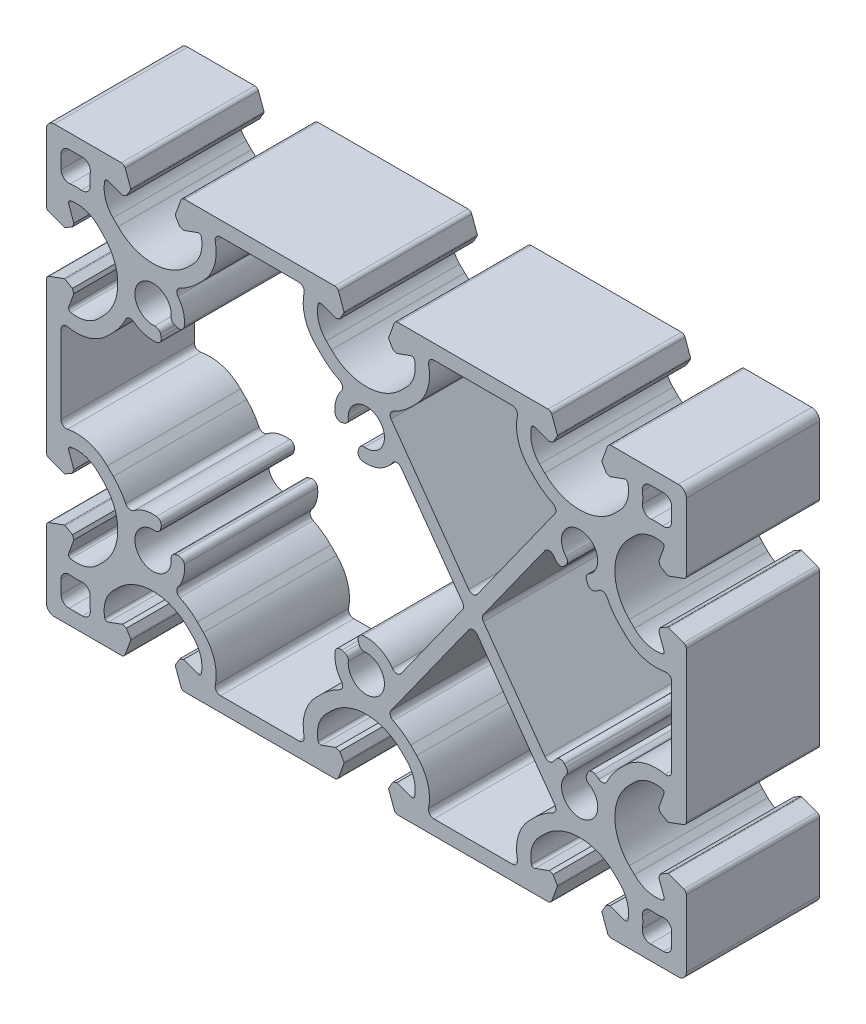
from build123d import *

# Parameters (mm, degrees)
MAIN_EXTRUSION_DEPTH = 25


with BuildPart() as part:
    # Sk Main Extrusion → Main Extrusion (new body)
    with BuildSketch(Plane.XY):
        with BuildLine():
            Line((-35.809923155, -36.671180212), (-34.777945649, -39.506515107))
            ThreePointArc((-34.777945649, -39.506515107), (-34.503358511, -39.864364033), (-34.073176184, -40))
            Line((-34.073176184, -40), (-5.926823816, -40))
            ThreePointArc((-5.926823816, -40), (-5.496641489, -39.864364033), (-5.222054351, -39.506515107))
            Line((-5.222054351, -39.506515107), (-4.190076845, -36.671180212))
            ThreePointArc((-4.190076845, -36.671180212), (-4.175951325, -36.563886241), (-4.208493649, -36.460675177))
            Line((-4.208493649, -36.460675177), (-4.987558066, -35.111296024))
            Line((-4.987558066, -35.111296024), (-5.718509166, -34.845251581))
            Line((-5.718509166, -34.845251581), (-8.396186179, -35.81984631))
            ThreePointArc((-8.396186179, -35.81984631), (-8.811074612, -35.786489799), (-9.056960151, -35.450654467))
            ThreePointArc((-9.056960151, -35.450654467), (-8.933433013, -32.665882372), (-7.504160339, -30.272684887))
            Line((-7.504160339, -30.272684887), (-6.540737726, -29.309262274))
            ThreePointArc((-6.540737726, -29.309262274), (0, -26.6), (6.540737726, -29.309262274))
            Line((6.540737726, -29.309262274), (7.504160339, -30.272684887))
            ThreePointArc((7.504160339, -30.272684887), (8.933433013, -32.665882372), (9.056960151, -35.450654467))
            ThreePointArc((9.056960151, -35.450654467), (8.811074612, -35.786489799), (8.396186179, -35.81984631))
            Line((8.396186179, -35.81984631), (5.718509166, -34.845251581))
            Line((5.718509166, -34.845251581), (4.987558066, -35.111296024))
            Line((4.987558066, -35.111296024), (4.208493649, -36.460675177))
            ThreePointArc((4.208493649, -36.460675177), (4.175951325, -36.563886241), (4.190076845, -36.671180212))
            Line((4.190076845, -36.671180212), (5.222054351, -39.506515107))
            ThreePointArc((5.222054351, -39.506515107), (5.496641489, -39.864364033), (5.926823816, -40))
            Line((5.926823816, -40), (34.073176184, -40))
            ThreePointArc((34.073176184, -40), (34.503358511, -39.864364033), (34.777945649, -39.506515107))
            Line((34.777945649, -39.506515107), (35.809923155, -36.671180212))
            ThreePointArc((35.809923155, -36.671180212), (35.824048675, -36.563886241), (35.791506351, -36.460675177))
            Line((35.791506351, -36.460675177), (35.012441934, -35.111296024))
            Line((35.012441934, -35.111296024), (34.281490834, -34.845251581))
            Line((34.281490834, -34.845251581), (31.603813821, -35.81984631))
            ThreePointArc((31.603813821, -35.81984631), (31.188925388, -35.786489799), (30.943039849, -35.450654467))
            ThreePointArc((30.943039849, -35.450654467), (31.066566987, -32.665882372), (32.495839661, -30.272684887))
            Line((32.495839661, -30.272684887), (33.459262274, -29.309262274))
            ThreePointArc((33.459262274, -29.309262274), (40, -26.6), (46.540737726, -29.309262274))
            Line((46.540737726, -29.309262274), (47.504160339, -30.272684887))
            ThreePointArc((47.504160339, -30.272684887), (48.933433013, -32.665882372), (49.056960151, -35.450654467))
            ThreePointArc((49.056960151, -35.450654467), (48.811074612, -35.786489799), (48.396186179, -35.81984631))
            Line((48.396186179, -35.81984631), (45.718509166, -34.845251581))
            Line((45.718509166, -34.845251581), (44.987558066, -35.111296024))
            Line((44.987558066, -35.111296024), (44.208493649, -36.460675176))
            ThreePointArc((44.208493649, -36.460675176), (44.175951325, -36.563886241), (44.190076845, -36.671180212))
            Line((44.190076845, -36.671180212), (45.222054351, -39.506515107))
            ThreePointArc((45.222054351, -39.506515107), (45.496641489, -39.864364033), (45.926823816, -40))
            Line((45.926823816, -40), (58.5, -40))
            ThreePointArc((58.5, -40), (59.560660172, -39.560660172), (60, -38.5))
            Line((60, -38.5), (60, -25.926823816))
            ThreePointArc((60, -25.926823816), (59.864364033, -25.496641489), (59.506515107, -25.222054351))
            Line((59.506515107, -25.222054351), (56.671180212, -24.190076845))
            ThreePointArc((56.671180212, -24.190076845), (56.563886241, -24.175951325), (56.460675176, -24.208493649))
            Line((56.460675176, -24.208493649), (55.111296024, -24.987558066))
            Line((55.111296024, -24.987558066), (54.845251581, -25.718509166))
            Line((54.845251581, -25.718509166), (55.81984631, -28.396186179))
            ThreePointArc((55.81984631, -28.396186179), (55.786489799, -28.811074612), (55.450654467, -29.056960151))
            ThreePointArc((55.450654467, -29.056960151), (52.665882372, -28.933433013), (50.272684887, -27.504160339))
            Line((50.272684887, -27.504160339), (49.309262274, -26.540737726))
            ThreePointArc((49.309262274, -26.540737726), (46.6, -20), (49.309262274, -13.459262274))
            Line((49.309262274, -13.459262274), (50.272684887, -12.495839661))
            ThreePointArc((50.272684887, -12.495839661), (52.665882372, -11.066566987), (55.450654467, -10.943039849))
            ThreePointArc((55.450654467, -10.943039849), (55.786489799, -11.188925388), (55.81984631, -11.603813821))
            Line((55.81984631, -11.603813821), (54.845251581, -14.281490834))
            Line((54.845251581, -14.281490834), (55.111296024, -15.012441934))
            Line((55.111296024, -15.012441934), (56.460675176, -15.791506351))
            ThreePointArc((56.460675176, -15.791506351), (56.563886241, -15.824048675), (56.671180212, -15.809923155))
            Line((56.671180212, -15.809923155), (59.506515107, -14.777945649))
            ThreePointArc((59.506515107, -14.777945649), (59.864364033, -14.503358511), (60, -14.073176184))
            Line((60, -14.073176184), (60, 14.073176184))
            ThreePointArc((60, 14.073176184), (59.864364033, 14.503358511), (59.506515107, 14.777945649))
            Line((59.506515107, 14.777945649), (56.671180212, 15.809923155))
            ThreePointArc((56.671180212, 15.809923155), (56.563886241, 15.824048675), (56.460675176, 15.791506351))
            Line((56.460675176, 15.791506351), (55.111296024, 15.012441934))
            Line((55.111296024, 15.012441934), (54.845251581, 14.281490834))
            Line((54.845251581, 14.281490834), (55.81984631, 11.603813821))
            ThreePointArc((55.81984631, 11.603813821), (55.786489799, 11.188925388), (55.450654467, 10.943039849))
            ThreePointArc((55.450654467, 10.943039849), (52.665882372, 11.066566987), (50.272684887, 12.495839661))
            Line((50.272684887, 12.495839661), (49.309262274, 13.459262274))
            ThreePointArc((49.309262274, 13.459262274), (46.6, 20), (49.309262274, 26.540737726))
            Line((49.309262274, 26.540737726), (50.272684887, 27.504160339))
            ThreePointArc((50.272684887, 27.504160339), (52.665882372, 28.933433013), (55.450654467, 29.056960151))
            ThreePointArc((55.450654467, 29.056960151), (55.786489799, 28.811074612), (55.81984631, 28.396186179))
            Line((55.81984631, 28.396186179), (54.845251581, 25.718509166))
            Line((54.845251581, 25.718509166), (55.111296024, 24.987558066))
            Line((55.111296024, 24.987558066), (56.460675176, 24.208493649))
            ThreePointArc((56.460675176, 24.208493649), (56.563886241, 24.175951325), (56.671180212, 24.190076845))
            Line((56.671180212, 24.190076845), (59.506515107, 25.222054351))
            ThreePointArc((59.506515107, 25.222054351), (59.864364033, 25.496641489), (60, 25.926823816))
            Line((60, 25.926823816), (60, 38.5))
            ThreePointArc((60, 38.5), (59.560660172, 39.560660172), (58.5, 40))
            Line((58.5, 40), (45.926823816, 40))
            ThreePointArc((45.926823816, 40), (45.496641489, 39.864364033), (45.222054351, 39.506515107))
            Line((45.222054351, 39.506515107), (44.190076845, 36.671180212))
            ThreePointArc((44.190076845, 36.671180212), (44.175951325, 36.563886241), (44.208493649, 36.460675177))
            Line((44.208493649, 36.460675177), (44.987558066, 35.111296024))
            Line((44.987558066, 35.111296024), (45.718509166, 34.845251581))
            Line((45.718509166, 34.845251581), (48.396186179, 35.81984631))
            ThreePointArc((48.396186179, 35.81984631), (48.811074612, 35.786489799), (49.056960151, 35.450654467))
            ThreePointArc((49.056960151, 35.450654467), (48.933433013, 32.665882372), (47.504160339, 30.272684887))
            Line((47.504160339, 30.272684887), (46.540737726, 29.309262274))
            ThreePointArc((46.540737726, 29.309262274), (40, 26.6), (33.459262274, 29.309262274))
            Line((33.459262274, 29.309262274), (32.495839661, 30.272684887))
            ThreePointArc((32.495839661, 30.272684887), (31.066566987, 32.665882372), (30.943039849, 35.450654467))
            ThreePointArc((30.943039849, 35.450654467), (31.188925388, 35.786489799), (31.603813821, 35.81984631))
            Line((31.603813821, 35.81984631), (34.281490834, 34.845251581))
            Line((34.281490834, 34.845251581), (35.012441934, 35.111296024))
            Line((35.012441934, 35.111296024), (35.791506351, 36.460675177))
            ThreePointArc((35.791506351, 36.460675177), (35.824048675, 36.563886241), (35.809923155, 36.671180212))
            Line((35.809923155, 36.671180212), (34.777945649, 39.506515107))
            ThreePointArc((34.777945649, 39.506515107), (34.503358511, 39.864364033), (34.073176184, 40))
            Line((34.073176184, 40), (5.926823816, 40))
            ThreePointArc((5.926823816, 40), (5.496641489, 39.864364033), (5.222054351, 39.506515107))
            Line((5.222054351, 39.506515107), (4.190076845, 36.671180212))
            ThreePointArc((4.190076845, 36.671180212), (4.175951325, 36.563886241), (4.208493649, 36.460675177))
            Line((4.208493649, 36.460675177), (4.987558066, 35.111296024))
            Line((4.987558066, 35.111296024), (5.718509166, 34.845251581))
            Line((5.718509166, 34.845251581), (8.396186179, 35.81984631))
            ThreePointArc((8.396186179, 35.81984631), (8.811074612, 35.786489799), (9.056960151, 35.450654467))
            ThreePointArc((9.056960151, 35.450654467), (8.933433013, 32.665882372), (7.504160339, 30.272684887))
            Line((7.504160339, 30.272684887), (6.540737726, 29.309262274))
            ThreePointArc((6.540737726, 29.309262274), (0, 26.6), (-6.540737726, 29.309262274))
            Line((-6.540737726, 29.309262274), (-7.504160339, 30.272684887))
            ThreePointArc((-7.504160339, 30.272684887), (-8.933433013, 32.665882372), (-9.056960151, 35.450654467))
            ThreePointArc((-9.056960151, 35.450654467), (-8.811074612, 35.786489799), (-8.396186179, 35.81984631))
            Line((-8.396186179, 35.81984631), (-5.718509166, 34.845251581))
            Line((-5.718509166, 34.845251581), (-4.987558066, 35.111296024))
            Line((-4.987558066, 35.111296024), (-4.208493649, 36.460675177))
            ThreePointArc((-4.208493649, 36.460675177), (-4.175951325, 36.563886241), (-4.190076845, 36.671180212))
            Line((-4.190076845, 36.671180212), (-5.222054351, 39.506515107))
            ThreePointArc((-5.222054351, 39.506515107), (-5.496641489, 39.864364033), (-5.926823816, 40))
            Line((-5.926823816, 40), (-34.073176184, 40))
            ThreePointArc((-34.073176184, 40), (-34.503358511, 39.864364033), (-34.777945649, 39.506515107))
            Line((-34.777945649, 39.506515107), (-35.809923155, 36.671180212))
            ThreePointArc((-35.809923155, 36.671180212), (-35.824048675, 36.563886241), (-35.791506351, 36.460675177))
            Line((-35.791506351, 36.460675177), (-35.012441934, 35.111296024))
            Line((-35.012441934, 35.111296024), (-34.281490834, 34.845251581))
            Line((-34.281490834, 34.845251581), (-31.603813821, 35.81984631))
            ThreePointArc((-31.603813821, 35.81984631), (-31.188925388, 35.786489799), (-30.943039849, 35.450654467))
            ThreePointArc((-30.943039849, 35.450654467), (-31.066566987, 32.665882372), (-32.495839661, 30.272684887))
            Line((-32.495839661, 30.272684887), (-33.459262274, 29.309262274))
            ThreePointArc((-33.459262274, 29.309262274), (-40, 26.6), (-46.540737726, 29.309262274))
            Line((-46.540737726, 29.309262274), (-47.504160339, 30.272684887))
            ThreePointArc((-47.504160339, 30.272684887), (-48.933433013, 32.665882372), (-49.056960151, 35.450654467))
            ThreePointArc((-49.056960151, 35.450654467), (-48.811074612, 35.786489799), (-48.396186179, 35.81984631))
            Line((-48.396186179, 35.81984631), (-45.718509166, 34.845251581))
            Line((-45.718509166, 34.845251581), (-44.987558066, 35.111296024))
            Line((-44.987558066, 35.111296024), (-44.208493649, 36.460675177))
            ThreePointArc((-44.208493649, 36.460675177), (-44.175951325, 36.563886241), (-44.190076845, 36.671180212))
            Line((-44.190076845, 36.671180212), (-45.222054351, 39.506515107))
            ThreePointArc((-45.222054351, 39.506515107), (-45.496641489, 39.864364033), (-45.926823816, 40))
            Line((-45.926823816, 40), (-58.5, 40))
            ThreePointArc((-58.5, 40), (-59.560660172, 39.560660172), (-60, 38.5))
            Line((-60, 38.5), (-60, 25.926823816))
            ThreePointArc((-60, 25.926823816), (-59.864364033, 25.496641489), (-59.506515108, 25.222054351))
            Line((-59.506515108, 25.222054351), (-56.671180212, 24.190076845))
            ThreePointArc((-56.671180212, 24.190076845), (-56.563886241, 24.175951325), (-56.460675177, 24.208493649))
            Line((-56.460675177, 24.208493649), (-55.111296024, 24.987558066))
            Line((-55.111296024, 24.987558066), (-54.845251581, 25.718509166))
            Line((-54.845251581, 25.718509166), (-55.81984631, 28.396186179))
            ThreePointArc((-55.81984631, 28.396186179), (-55.786489799, 28.811074612), (-55.450654467, 29.056960151))
            ThreePointArc((-55.450654467, 29.056960151), (-52.665882372, 28.933433013), (-50.272684887, 27.504160339))
            Line((-50.272684887, 27.504160339), (-49.309262274, 26.540737726))
            ThreePointArc((-49.309262274, 26.540737726), (-46.6, 20), (-49.309262274, 13.459262274))
            Line((-49.309262274, 13.459262274), (-50.272684887, 12.495839661))
            ThreePointArc((-50.272684887, 12.495839661), (-52.665882372, 11.066566987), (-55.450654467, 10.943039849))
            ThreePointArc((-55.450654467, 10.943039849), (-55.786489799, 11.188925388), (-55.81984631, 11.603813821))
            Line((-55.81984631, 11.603813821), (-54.845251581, 14.281490834))
            Line((-54.845251581, 14.281490834), (-55.111296024, 15.012441934))
            Line((-55.111296024, 15.012441934), (-56.460675177, 15.791506351))
            ThreePointArc((-56.460675177, 15.791506351), (-56.563886241, 15.824048675), (-56.671180212, 15.809923155))
            Line((-56.671180212, 15.809923155), (-59.506515108, 14.777945649))
            ThreePointArc((-59.506515108, 14.777945649), (-59.864364033, 14.503358511), (-60, 14.073176184))
            Line((-60, 14.073176184), (-60, -14.073176184))
            ThreePointArc((-60, -14.073176184), (-59.864364033, -14.503358511), (-59.506515108, -14.777945649))
            Line((-59.506515108, -14.777945649), (-56.671180212, -15.809923155))
            ThreePointArc((-56.671180212, -15.809923155), (-56.563886241, -15.824048675), (-56.460675177, -15.791506351))
            Line((-56.460675177, -15.791506351), (-55.111296024, -15.012441934))
            Line((-55.111296024, -15.012441934), (-54.845251581, -14.281490834))
            Line((-54.845251581, -14.281490834), (-55.81984631, -11.603813821))
            ThreePointArc((-55.81984631, -11.603813821), (-55.786489799, -11.188925388), (-55.450654467, -10.943039849))
            ThreePointArc((-55.450654467, -10.943039849), (-52.665882372, -11.066566987), (-50.272684887, -12.495839661))
            Line((-50.272684887, -12.495839661), (-49.309262274, -13.459262274))
            ThreePointArc((-49.309262274, -13.459262274), (-46.6, -20), (-49.309262274, -26.540737726))
            Line((-49.309262274, -26.540737726), (-50.272684887, -27.504160339))
            ThreePointArc((-50.272684887, -27.504160339), (-52.665882372, -28.933433013), (-55.450654467, -29.056960151))
            ThreePointArc((-55.450654467, -29.056960151), (-55.786489799, -28.811074612), (-55.81984631, -28.396186179))
            Line((-55.81984631, -28.396186179), (-54.845251581, -25.718509166))
            Line((-54.845251581, -25.718509166), (-55.111296024, -24.987558066))
            Line((-55.111296024, -24.987558066), (-56.460675177, -24.208493649))
            ThreePointArc((-56.460675177, -24.208493649), (-56.563886241, -24.175951325), (-56.671180212, -24.190076845))
            Line((-56.671180212, -24.190076845), (-59.506515108, -25.222054351))
            ThreePointArc((-59.506515108, -25.222054351), (-59.864364033, -25.496641489), (-60, -25.926823816))
            Line((-60, -25.926823816), (-60, -38.5))
            ThreePointArc((-60, -38.5), (-59.560660172, -39.560660172), (-58.5, -40))
            Line((-58.5, -40), (-45.926823816, -40))
            ThreePointArc((-45.926823816, -40), (-45.496641489, -39.864364033), (-45.222054351, -39.506515107))
            Line((-45.222054351, -39.506515107), (-44.190076845, -36.671180212))
            ThreePointArc((-44.190076845, -36.671180212), (-44.175951325, -36.563886241), (-44.208493649, -36.460675177))
            Line((-44.208493649, -36.460675177), (-44.987558066, -35.111296024))
            Line((-44.987558066, -35.111296024), (-45.718509166, -34.845251581))
            Line((-45.718509166, -34.845251581), (-48.396186179, -35.81984631))
            ThreePointArc((-48.396186179, -35.81984631), (-48.811074612, -35.786489799), (-49.056960151, -35.450654467))
            ThreePointArc((-49.056960151, -35.450654467), (-48.933433013, -32.665882372), (-47.504160339, -30.272684887))
            Line((-47.504160339, -30.272684887), (-46.540737726, -29.309262274))
            ThreePointArc((-46.540737726, -29.309262274), (-40, -26.6), (-33.459262274, -29.309262274))
            Line((-33.459262274, -29.309262274), (-32.495839661, -30.272684887))
            ThreePointArc((-32.495839661, -30.272684887), (-31.066566987, -32.665882372), (-30.943039849, -35.450654467))
            ThreePointArc((-30.943039849, -35.450654467), (-31.188925388, -35.786489799), (-31.603813821, -35.81984631))
            Line((-31.603813821, -35.81984631), (-34.281490834, -34.845251581))
            Line((-34.281490834, -34.845251581), (-35.012441934, -35.111296024))
            Line((-35.012441934, -35.111296024), (-35.791506351, -36.460675177))
            ThreePointArc((-35.791506351, -36.460675177), (-35.824048675, -36.563886241), (-35.809923155, -36.671180212))
        make_face()
        with BuildLine():
            Line((-57.25, 35.75), (-57.25, 33.248136122))
            ThreePointArc((-57.25, 33.248136122), (-56.732645411, 32.114818869), (-55.537456006, 31.763270791))
            ThreePointArc((-55.537456006, 31.763270791), (-54.496293642, 31.845117953), (-53.453172645, 31.793965142))
            ThreePointArc((-53.453172645, 31.793965142), (-52.223785121, 32.223785121), (-51.793965142, 33.453172645))
            ThreePointArc((-51.793965142, 33.453172645), (-51.845117953, 34.496293642), (-51.763270791, 35.537456006))
            ThreePointArc((-51.763270791, 35.537456006), (-52.114818869, 36.732645411), (-53.248136122, 37.25))
            Line((-53.248136122, 37.25), (-55.75, 37.25))
            ThreePointArc((-55.75, 37.25), (-56.810660172, 36.810660172), (-57.25, 35.75))
        make_face(mode=Mode.SUBTRACT)
        with BuildLine():
            Line((-38.613973161, 15.878920058), (-38.482943859, 15.389912045))
            ThreePointArc((-38.482943859, 15.389912045), (-38.622486067, 14.567985447), (-39.336394111, 14.13743851))
            ThreePointArc((-39.336394111, 14.13743851), (-41.591923558, 14.318822359), (-43.613291925, 15.335868627))
            ThreePointArc((-43.613291925, 15.335868627), (-44.458362439, 15.517898854), (-45.129579832, 14.973154523))
            ThreePointArc((-45.129579832, 14.973154523), (-46.144357349, 13.232864029), (-47.441495321, 11.691495321))
            Line((-47.441495321, 11.691495321), (-48.577273231, 10.555717411))
            ThreePointArc((-48.577273231, 10.555717411), (-52.029888718, 8.496647498), (-56.046255308, 8.325995764))
            ThreePointArc((-56.046255308, 8.325995764), (-56.880973576, 8.122776031), (-57.25, 7.346971709))
            Line((-57.25, 7.346971709), (-57.25, -7.346971709))
            ThreePointArc((-57.25, -7.346971709), (-56.880973576, -8.122776031), (-56.046255308, -8.325995764))
            ThreePointArc((-56.046255308, -8.325995764), (-52.029888718, -8.496647498), (-48.577273231, -10.555717411))
            Line((-48.577273231, -10.555717411), (-47.441495321, -11.691495321))
            ThreePointArc((-47.441495321, -11.691495321), (-46.144357349, -13.232864029), (-45.129579832, -14.973154523))
            ThreePointArc((-45.129579832, -14.973154523), (-44.458362439, -15.517898854), (-43.613291925, -15.335868627))
            ThreePointArc((-43.613291925, -15.335868627), (-41.591923558, -14.318822359), (-39.336394111, -14.13743851))
            ThreePointArc((-39.336394111, -14.13743851), (-38.622486067, -14.567985447), (-38.482943859, -15.389912045))
            Line((-38.482943859, -15.389912045), (-38.613973161, -15.878920058))
            ThreePointArc((-38.613973161, -15.878920058), (-39.009750252, -16.441642502), (-39.67537649, -16.615532601))
            ThreePointArc((-39.67537649, -16.615532601), (-42.404163056, -22.404163056), (-36.615532601, -19.67537649))
            ThreePointArc((-36.615532601, -19.67537649), (-36.441642502, -19.009750252), (-35.878920058, -18.613973161))
            Line((-35.878920058, -18.613973161), (-35.389912045, -18.482943859))
            ThreePointArc((-35.389912045, -18.482943859), (-34.567985447, -18.622486067), (-34.13743851, -19.336394111))
            ThreePointArc((-34.13743851, -19.336394111), (-34.318822359, -21.591923558), (-35.335868627, -23.613291925))
            ThreePointArc((-35.335868627, -23.613291925), (-35.517898854, -24.458362439), (-34.973154523, -25.129579832))
            ThreePointArc((-34.973154523, -25.129579832), (-33.232864029, -26.144357349), (-31.691495321, -27.441495321))
            Line((-31.691495321, -27.441495321), (-30.555717411, -28.577273231))
            ThreePointArc((-30.555717411, -28.577273231), (-28.496647498, -32.029888718), (-28.325995764, -36.046255308))
            ThreePointArc((-28.325995764, -36.046255308), (-28.122776031, -36.880973576), (-27.346971709, -37.25))
            Line((-27.346971709, -37.25), (-12.653028291, -37.25))
            ThreePointArc((-12.653028291, -37.25), (-11.877223969, -36.880973576), (-11.674004236, -36.046255308))
            ThreePointArc((-11.674004236, -36.046255308), (-11.503352502, -32.029888718), (-9.444282589, -28.577273231))
            Line((-9.444282589, -28.577273231), (-8.308504679, -27.441495321))
            ThreePointArc((-8.308504679, -27.441495321), (-6.767135971, -26.144357349), (-5.026845477, -25.129579832))
            ThreePointArc((-5.026845477, -25.129579832), (-4.482101146, -24.458362439), (-4.664131373, -23.613291925))
            ThreePointArc((-4.664131373, -23.613291925), (-5.681177641, -21.591923558), (-5.86256149, -19.336394111))
            ThreePointArc((-5.86256149, -19.336394111), (-5.432014553, -18.622486067), (-4.610087955, -18.482943859))
            Line((-4.610087955, -18.482943859), (-4.121079942, -18.613973161))
            ThreePointArc((-4.121079942, -18.613973161), (-3.558357498, -19.009750252), (-3.384467399, -19.67537649))
            ThreePointArc((-3.384467399, -19.67537649), (2.404163056, -22.404163056), (-0.32462351, -16.615532601))
            ThreePointArc((-0.32462351, -16.615532601), (-0.990249748, -16.441642502), (-1.386026839, -15.878920058))
            Line((-1.386026839, -15.878920058), (-1.517056141, -15.389912045))
            ThreePointArc((-1.517056141, -15.389912045), (-1.377513933, -14.567985447), (-0.663605889, -14.13743851))
            ThreePointArc((-0.663605889, -14.13743851), (2.467010539, -14.640535568), (4.88510203, -16.691559558))
            ThreePointArc((4.88510203, -16.691559558), (5.700607787, -17.130729092), (6.526818353, -16.712045896))
            Line((6.526818353, -16.712045896), (18.048846092, -0.581238955))
            ThreePointArc((18.048846092, -0.581238955), (18.235113164, 0), (18.048846092, 0.581238955))
            Line((18.048846092, 0.581238955), (6.526818353, 16.712045896))
            ThreePointArc((6.526818353, 16.712045896), (5.700607787, 17.130729092), (4.88510203, 16.691559558))
            ThreePointArc((4.88510203, 16.691559558), (2.467010539, 14.640535568), (-0.663605889, 14.13743851))
            ThreePointArc((-0.663605889, 14.13743851), (-1.377513933, 14.567985447), (-1.517056141, 15.389912045))
            Line((-1.517056141, 15.389912045), (-1.386026839, 15.878920058))
            ThreePointArc((-1.386026839, 15.878920058), (-0.990249748, 16.441642502), (-0.32462351, 16.615532601))
            ThreePointArc((-0.32462351, 16.615532601), (2.404163056, 22.404163056), (-3.384467399, 19.67537649))
            ThreePointArc((-3.384467399, 19.67537649), (-3.558357498, 19.009750252), (-4.121079942, 18.613973161))
            Line((-4.121079942, 18.613973161), (-4.610087955, 18.482943859))
            ThreePointArc((-4.610087955, 18.482943859), (-5.432014553, 18.622486067), (-5.86256149, 19.336394111))
            ThreePointArc((-5.86256149, 19.336394111), (-5.681177641, 21.591923558), (-4.664131373, 23.613291925))
            ThreePointArc((-4.664131373, 23.613291925), (-4.482101146, 24.458362439), (-5.026845477, 25.129579832))
            ThreePointArc((-5.026845477, 25.129579832), (-6.767135971, 26.144357349), (-8.308504679, 27.441495321))
            Line((-8.308504679, 27.441495321), (-9.444282589, 28.577273231))
            ThreePointArc((-9.444282589, 28.577273231), (-11.503352502, 32.029888718), (-11.674004236, 36.046255308))
            ThreePointArc((-11.674004236, 36.046255308), (-11.877223969, 36.880973576), (-12.653028291, 37.25))
            Line((-12.653028291, 37.25), (-27.346971709, 37.25))
            ThreePointArc((-27.346971709, 37.25), (-28.122776031, 36.880973576), (-28.325995764, 36.046255308))
            ThreePointArc((-28.325995764, 36.046255308), (-28.496647498, 32.029888718), (-30.555717411, 28.577273231))
            Line((-30.555717411, 28.577273231), (-31.691495321, 27.441495321))
            ThreePointArc((-31.691495321, 27.441495321), (-33.232864029, 26.144357349), (-34.973154523, 25.129579832))
            ThreePointArc((-34.973154523, 25.129579832), (-35.517898854, 24.458362439), (-35.335868627, 23.613291925))
            ThreePointArc((-35.335868627, 23.613291925), (-34.318822359, 21.591923558), (-34.13743851, 19.336394111))
            ThreePointArc((-34.13743851, 19.336394111), (-34.567985447, 18.622486067), (-35.389912045, 18.482943859))
            Line((-35.389912045, 18.482943859), (-35.878920058, 18.613973161))
            ThreePointArc((-35.878920058, 18.613973161), (-36.441642502, 19.009750252), (-36.615532601, 19.67537649))
            ThreePointArc((-36.615532601, 19.67537649), (-42.404163056, 22.404163056), (-39.67537649, 16.615532601))
            ThreePointArc((-39.67537649, 16.615532601), (-39.009750252, 16.441642502), (-38.613973161, 15.878920058))
        make_face(mode=Mode.SUBTRACT)
        with BuildLine():
            Line((20.813732928, 3.289594962), (35.354506019, 23.646637041))
            ThreePointArc((35.354506019, 23.646637041), (35.508678856, 24.479189408), (34.968947751, 25.131571996))
            ThreePointArc((34.968947751, 25.131571996), (33.230961575, 26.145697901), (31.691495321, 27.441495321))
            Line((31.691495321, 27.441495321), (30.555717411, 28.577273231))
            ThreePointArc((30.555717411, 28.577273231), (28.496647498, 32.029888718), (28.325995764, 36.046255308))
            ThreePointArc((28.325995764, 36.046255308), (28.122776031, 36.880973576), (27.346971709, 37.25))
            Line((27.346971709, 37.25), (12.653028291, 37.25))
            ThreePointArc((12.653028291, 37.25), (11.877223969, 36.880973576), (11.674004236, 36.046255308))
            ThreePointArc((11.674004236, 36.046255308), (11.503352502, 32.029888718), (9.444282589, 28.577273231))
            Line((9.444282589, 28.577273231), (8.308504679, 27.441495321))
            ThreePointArc((8.308504679, 27.441495321), (6.769038425, 26.145697901), (5.031052249, 25.131571996))
            ThreePointArc((5.031052249, 25.131571996), (4.491321144, 24.479189408), (4.645493981, 23.646637041))
            Line((4.645493981, 23.646637041), (19.186267072, 3.289594962))
            ThreePointArc((19.186267072, 3.289594962), (20, 2.870833917), (20.813732928, 3.289594962))
        make_face(mode=Mode.SUBTRACT)
        with BuildLine():
            Line((-57.25, -33.248136122), (-57.25, -35.75))
            ThreePointArc((-57.25, -35.75), (-56.810660172, -36.810660172), (-55.75, -37.25))
            Line((-55.75, -37.25), (-53.248136122, -37.25))
            ThreePointArc((-53.248136122, -37.25), (-52.114818869, -36.732645411), (-51.763270791, -35.537456006))
            ThreePointArc((-51.763270791, -35.537456006), (-51.845117953, -34.496293642), (-51.793965142, -33.453172645))
            ThreePointArc((-51.793965142, -33.453172645), (-52.223785121, -32.223785121), (-53.453172645, -31.793965142))
            ThreePointArc((-53.453172645, -31.793965142), (-54.496293642, -31.845117953), (-55.537456006, -31.763270791))
            ThreePointArc((-55.537456006, -31.763270791), (-56.732645411, -32.114818869), (-57.25, -33.248136122))
        make_face(mode=Mode.SUBTRACT)
        with BuildLine():
            Line((19.186267072, -3.289594962), (4.645493981, -23.646637041))
            ThreePointArc((4.645493981, -23.646637041), (4.491321144, -24.479189408), (5.031052249, -25.131571996))
            ThreePointArc((5.031052249, -25.131571996), (6.769038425, -26.145697901), (8.308504679, -27.441495321))
            Line((8.308504679, -27.441495321), (9.444282589, -28.577273231))
            ThreePointArc((9.444282589, -28.577273231), (11.503352502, -32.029888718), (11.674004236, -36.046255308))
            ThreePointArc((11.674004236, -36.046255308), (11.877223969, -36.880973576), (12.653028291, -37.25))
            Line((12.653028291, -37.25), (27.346971709, -37.25))
            ThreePointArc((27.346971709, -37.25), (28.122776031, -36.880973576), (28.325995764, -36.046255308))
            ThreePointArc((28.325995764, -36.046255308), (28.496647498, -32.029888718), (30.555717411, -28.577273231))
            Line((30.555717411, -28.577273231), (31.691495321, -27.441495321))
            ThreePointArc((31.691495321, -27.441495321), (33.230961575, -26.145697901), (34.968947751, -25.131571996))
            ThreePointArc((34.968947751, -25.131571996), (35.508678856, -24.479189408), (35.354506019, -23.646637041))
            Line((35.354506019, -23.646637041), (20.813732928, -3.289594962))
            ThreePointArc((20.813732928, -3.289594962), (20, -2.870833917), (19.186267072, -3.289594962))
        make_face(mode=Mode.SUBTRACT)
        with BuildLine():
            Line((41.29638202, -15.84984772), (41.477283726, -15.377013619))
            ThreePointArc((41.477283726, -15.377013619), (42.072644253, -14.793420265), (42.903355818, -14.863802477))
            ThreePointArc((42.903355818, -14.863802477), (43.266861807, -15.086995427), (43.613291925, -15.335868627))
            ThreePointArc((43.613291925, -15.335868627), (44.458362439, -15.517898854), (45.129579832, -14.973154523))
            ThreePointArc((45.129579832, -14.973154523), (46.144357349, -13.232864029), (47.441495321, -11.691495321))
            Line((47.441495321, -11.691495321), (48.577273231, -10.555717411))
            ThreePointArc((48.577273231, -10.555717411), (52.029888718, -8.496647498), (56.046255308, -8.325995764))
            ThreePointArc((56.046255308, -8.325995764), (56.880973576, -8.122776031), (57.25, -7.346971709))
            Line((57.25, -7.346971709), (57.25, 7.346971709))
            ThreePointArc((57.25, 7.346971709), (56.880973576, 8.122776031), (56.046255308, 8.325995764))
            ThreePointArc((56.046255308, 8.325995764), (52.029888718, 8.496647498), (48.577273231, 10.555717411))
            Line((48.577273231, 10.555717411), (47.441495321, 11.691495321))
            ThreePointArc((47.441495321, 11.691495321), (46.144357349, 13.232864029), (45.129579832, 14.973154523))
            ThreePointArc((45.129579832, 14.973154523), (44.458362439, 15.517898854), (43.613291925, 15.335868627))
            ThreePointArc((43.613291925, 15.335868627), (43.266861807, 15.086995427), (42.903355818, 14.863802477))
            ThreePointArc((42.903355818, 14.863802477), (42.072644253, 14.793420265), (41.477283726, 15.377013619))
            Line((41.477283726, 15.377013619), (41.29638202, 15.84984772))
            ThreePointArc((41.29638202, 15.84984772), (41.286576489, 16.537742993), (41.723459927, 17.069183411))
            ThreePointArc((41.723459927, 17.069183411), (40.535606701, 23.357547537), (37.450217607, 17.750864666))
            ThreePointArc((37.450217607, 17.750864666), (37.700071062, 17.109873787), (37.476728113, 16.459171104))
            Line((37.476728113, 16.459171104), (37.157692623, 16.06608858))
            ThreePointArc((37.157692623, 16.06608858), (36.410308442, 15.696694148), (35.642724919, 16.022041495))
            ThreePointArc((35.642724919, 16.022041495), (35.366702333, 16.347254084), (35.11489797, 16.691559558))
            ThreePointArc((35.11489797, 16.691559558), (34.299392213, 17.130729092), (33.473181647, 16.712045896))
            Line((33.473181647, 16.712045896), (21.951153908, 0.581238955))
            ThreePointArc((21.951153908, 0.581238955), (21.764886836, 0), (21.951153908, -0.581238955))
            Line((21.951153908, -0.581238955), (33.473181647, -16.712045896))
            ThreePointArc((33.473181647, -16.712045896), (34.299392213, -17.130729092), (35.11489797, -16.691559558))
            ThreePointArc((35.11489797, -16.691559558), (35.366702333, -16.347254084), (35.642724919, -16.022041495))
            ThreePointArc((35.642724919, -16.022041495), (36.410308442, -15.696694148), (37.157692623, -16.06608858))
            Line((37.157692623, -16.06608858), (37.476728113, -16.459171104))
            ThreePointArc((37.476728113, -16.459171104), (37.700071062, -17.109873787), (37.450217607, -17.750864666))
            ThreePointArc((37.450217607, -17.750864666), (40.535606701, -23.357547537), (41.723459927, -17.069183411))
            ThreePointArc((41.723459927, -17.069183411), (41.286576489, -16.537742993), (41.29638202, -15.84984772))
        make_face(mode=Mode.SUBTRACT)
        with BuildLine():
            Line((53.248136122, -37.25), (55.75, -37.25))
            ThreePointArc((55.75, -37.25), (56.810660172, -36.810660172), (57.25, -35.75))
            Line((57.25, -35.75), (57.25, -33.248136122))
            ThreePointArc((57.25, -33.248136122), (56.732645411, -32.114818869), (55.537456006, -31.763270791))
            ThreePointArc((55.537456006, -31.763270791), (54.496293642, -31.845117953), (53.453172645, -31.793965142))
            ThreePointArc((53.453172645, -31.793965142), (52.223785121, -32.223785121), (51.793965142, -33.453172645))
            ThreePointArc((51.793965142, -33.453172645), (51.845117953, -34.496293642), (51.763270791, -35.537456006))
            ThreePointArc((51.763270791, -35.537456006), (52.114818869, -36.732645411), (53.248136122, -37.25))
        make_face(mode=Mode.SUBTRACT)
        with BuildLine():
            Line((57.25, 33.248136122), (57.25, 35.75))
            ThreePointArc((57.25, 35.75), (56.810660172, 36.810660172), (55.75, 37.25))
            Line((55.75, 37.25), (53.248136122, 37.25))
            ThreePointArc((53.248136122, 37.25), (52.114818869, 36.732645411), (51.763270791, 35.537456006))
            ThreePointArc((51.763270791, 35.537456006), (51.845117953, 34.496293642), (51.793965142, 33.453172645))
            ThreePointArc((51.793965142, 33.453172645), (52.223785121, 32.223785121), (53.453172645, 31.793965142))
            ThreePointArc((53.453172645, 31.793965142), (54.496293642, 31.845117953), (55.537456006, 31.763270791))
            ThreePointArc((55.537456006, 31.763270791), (56.732645411, 32.114818869), (57.25, 33.248136122))
        make_face(mode=Mode.SUBTRACT)
    extrude(amount=-MAIN_EXTRUSION_DEPTH)


solid = part.part
